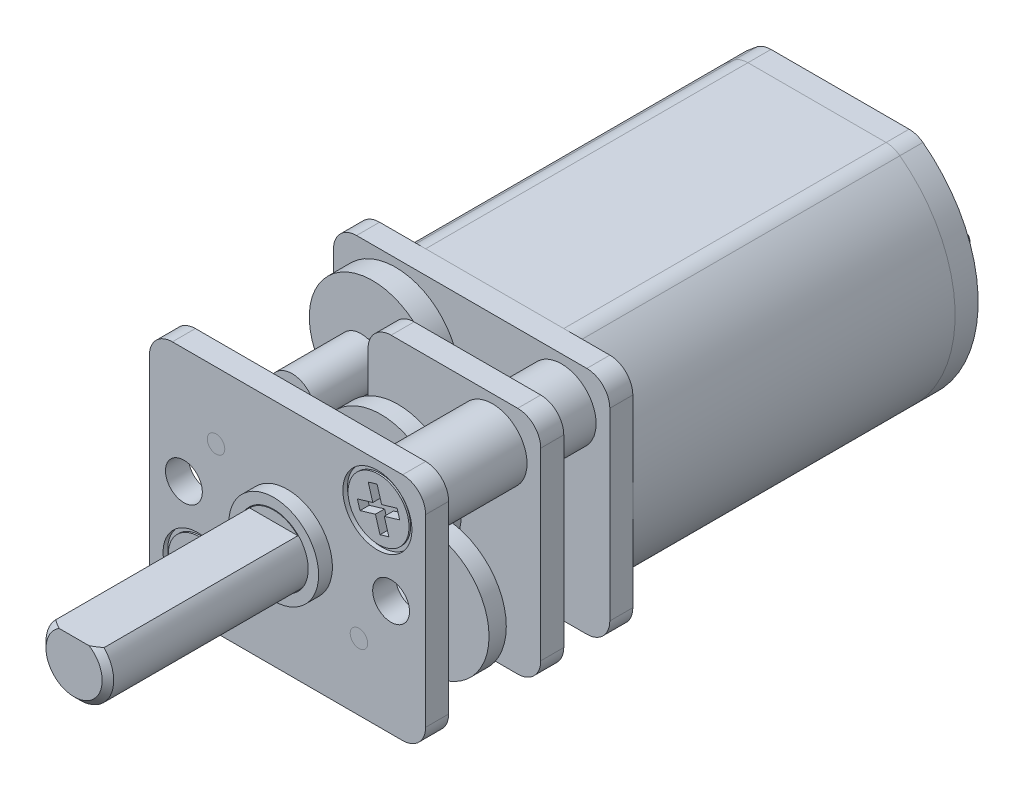
from build123d import *

# Parameters (mm, degrees)
BOSS_EXTRUDE1_DEPTH    = 7.5
FILLET3_R              = 1
BOSS_EXTRUDE2_DEPTH    = 1
BOSS_EXTRUDE3_START    = 9
BOSS_EXTRUDE3_DEPTH    = 1
SKETCH7_R              = 0.5
BOSS_EXTRUDE5_DEPTH    = 8
BOSS_EXTRUDE5_2_DEPTH  = 8
BOSS_EXTRUDE8_START    = 2
BOSS_EXTRUDE8_DEPTH    = 1
SKETCH5_R              = 0.75
SKETCH5_R_2            = 0.38
CUT_EXTRUDE1_DEPTH     = 9
SKETCH8_R              = 0.5
SKETCH8_R_2            = 0.38
CUT_EXTRUDE2_DEPTH     = 1
BOSS_EXTRUDE6_START    = 0.2
SKETCH9_R              = 2.75
SKETCH9_R_2            = 0.5
BOSS_EXTRUDE6_DEPTH    = 1
BOSS_EXTRUDE16_START   = 0.1
SKETCH9_3_R            = 1
SKETCH9_3_R_2          = 0.75
BOSS_EXTRUDE16_DEPTH   = 1.3
SKETCH6_R              = 1.95
SKETCH6_R_2            = 0.75
BOSS_EXTRUDE4_DEPTH    = 0.6
BOSS_EXTRUDE7_START    = 0.5
SKETCH10_R             = 1
SKETCH10_R_2           = 0.5
BOSS_EXTRUDE7_DEPTH    = 3
SKETCH12_R             = 1.5
SKETCH12_R_2           = 0.75
BOSS_EXTRUDE9_DEPTH    = 2
BOSS_EXTRUDE9_2_DEPTH  = 2
BOSS_EXTRUDE10_START   = 3
SKETCH12_2_R           = 1.5
SKETCH12_2_R_2         = 0.75
BOSS_EXTRUDE10_DEPTH   = 4
BOSS_EXTRUDE10_2_DEPTH = 4
SKETCH13_R             = 1.5
CUT_EXTRUDE3_DEPTH     = 7.2
SKETCH14_R             = 1.5
CUT_EXTRUDE4_DEPTH     = 0.2
CHAMFER1_SIZE          = 0.5
BOSS_EXTRUDE11_START   = 0.2
SKETCH15_R             = 2.75
BOSS_EXTRUDE11_DEPTH   = 0.75
BOSS_EXTRUDE12_START   = 0.2
SKETCH16_R             = 1
BOSS_EXTRUDE12_DEPTH   = 1.15
BOSS_EXTRUDE13_START   = 0.4
SKETCH17_R             = 2.75
BOSS_EXTRUDE13_DEPTH   = 0.75
BOSS_EXTRUDE14_START   = 0.2
SKETCH18_R             = 1
BOSS_EXTRUDE14_DEPTH   = 1.5
SKETCH19_R             = 0.5
CUT_EXTRUDE5_DEPTH     = 23.8
SKETCH20_R             = 2.75
BOSS_EXTRUDE15_DEPTH   = 1
SKETCH21_R             = 0.5
CUT_EXTRUDE6_DEPTH     = 7.8
CHAMFER2_SIZE          = 0.25
CUT_EXTRUDE7_DEPTH     = 8.67
SKETCH24_R             = 0.8
CUT_EXTRUDE8_DEPTH     = 1
CUT_EXTRUDE9_DEPTH     = 1
BOSS_EXTRUDE17_DEPTH   = 1
SKETCH27_R             = 2.5
BOSS_EXTRUDE18_DEPTH   = 1.5
SKETCH28_W             = 0.3
SKETCH28_H             = 1.5
BOSS_EXTRUDE19_DEPTH   = 2
BOSS_EXTRUDE19_2_DEPTH = 2
FILLET1_R              = 0.7
FILLET2_R              = 0.7
CUT_EXTRUDE10_DEPTH    = 0.4


with BuildPart() as part:
    # Sketch1 → Boss-Extrude1 (new body, symmetric)
    with BuildSketch(Plane.XY):
        with BuildLine():
            Line((3.31662479, 5), (-3.31662479, 5))
            ThreePointArc((-3.31662479, 5), (-6, 0), (-3.31662479, -5))
            Line((-3.31662479, -5), (3.31662479, -5))
            ThreePointArc((3.31662479, -5), (6, 0), (3.31662479, 5))
        make_face()
    extrude(amount=BOSS_EXTRUDE1_DEPTH, both=True)

    # Fillet3
    fillet3_edges = [part.edges().sort_by_distance(p)[0] for p in [
        (3.31662479, -5, 0),
        (-3.31662479, -5, 0),
        (-3.31662479, 5, 0),
        (3.31662479, 5, 0),
    ]]
    fillet(fillet3_edges, radius=FILLET3_R)

    # Sketch25 → Cut-Extrude9 (cut)
    with BuildSketch(Plane(origin=(0, 0, -7.5), x_dir=(-1, 0, 0), z_dir=(0, 0, -1))):
        with BuildLine():
            Line((-3, -5), (3, -5))
            ThreePointArc((3, -5), (3.316227766, -4.948683298), (3.6, -4.8))
            ThreePointArc((3.6, -4.8), (6, 0), (3.6, 4.8))
            ThreePointArc((3.6, 4.8), (3.316227766, 4.948683298), (3, 5))
            Line((3, 5), (-3, 5))
            ThreePointArc((-3, 5), (-3.316227766, 4.948683298), (-3.6, 4.8))
            ThreePointArc((-3.6, 4.8), (-6, 0), (-3.6, -4.8))
            ThreePointArc((-3.6, -4.8), (-3.316227766, -4.948683298), (-3, -5))
        make_face()
    extrude(amount=-CUT_EXTRUDE9_DEPTH, mode=Mode.SUBTRACT)


with BuildPart() as body_2:
    # Sketch2 → Boss-Extrude2 (new body)
    with BuildSketch(Plane.XY.offset(7.5)):
        with BuildLine():
            Line((-5, -5), (5, -5))
            ThreePointArc((5, -5), (5.707106781, -4.707106781), (6, -4))
            Line((6, -4), (6, 4))
            ThreePointArc((6, 4), (5.707106781, 4.707106781), (5, 5))
            Line((5, 5), (-5, 5))
            ThreePointArc((-5, 5), (-5.707106781, 4.707106781), (-6, 4))
            Line((-6, 4), (-6, -4))
            ThreePointArc((-6, -4), (-5.707106781, -4.707106781), (-5, -5))
        make_face()
    extrude(amount=BOSS_EXTRUDE2_DEPTH)


with BuildPart() as body_3:
    # Sketch2_2 → Boss-Extrude3 (new body)
    with BuildSketch(Plane.XY.offset(7.5).offset(BOSS_EXTRUDE3_START)):
        with BuildLine():
            Line((-5, -5), (5, -5))
            ThreePointArc((5, -5), (5.707106781, -4.707106781), (6, -4))
            Line((6, -4), (6, 4))
            ThreePointArc((6, 4), (5.707106781, 4.707106781), (5, 5))
            Line((5, 5), (-5, 5))
            ThreePointArc((-5, 5), (-5.707106781, 4.707106781), (-6, 4))
            Line((-6, 4), (-6, -4))
            ThreePointArc((-6, -4), (-5.707106781, -4.707106781), (-5, -5))
        make_face()
    extrude(amount=-BOSS_EXTRUDE3_DEPTH)


with BuildPart() as body_4:
    # Sketch7 → Boss-Extrude5 (new body)
    with BuildSketch(Plane.XY.offset(8.5)):
        with Locations((-3.104083332, 2.104083332)):
            Circle(SKETCH7_R)
    extrude(amount=BOSS_EXTRUDE5_DEPTH)


with BuildPart() as body_5:
    # Sketch7 → Boss-Extrude5 2 (new body)
    with BuildSketch(Plane.XY.offset(8.5)):
        with Locations((3.104083332, -2.104083332)):
            Circle(SKETCH7_R)
    extrude(amount=BOSS_EXTRUDE5_2_DEPTH)


with BuildPart() as body_6:
    # Sketch11 → Boss-Extrude8 (new body)
    with BuildSketch(Plane.XY.offset(8.5).offset(BOSS_EXTRUDE8_START)):
        with BuildLine():
            Line((-5, -1.25), (-2.5, -1.25))
            ThreePointArc((-2.5, -1.25), (-1.792893219, -0.957106781), (-1.5, -0.25))
            Line((-1.5, -0.25), (-1.5, 4))
            ThreePointArc((-1.5, 4), (-1.207106781, 4.707106781), (-0.5, 5))
            Line((-0.5, 5), (5, 5))
            ThreePointArc((5, 5), (5.707106781, 4.707106781), (6, 4))
            Line((6, 4), (6, -4))
            ThreePointArc((6, -4), (5.707106781, -4.707106781), (5, -5))
            Line((5, -5), (-5, -5))
            ThreePointArc((-5, -5), (-5.707106781, -4.707106781), (-6, -4))
            Line((-6, -4), (-6, -2.25))
            ThreePointArc((-6, -2.25), (-5.707106781, -1.542893219), (-5, -1.25))
        make_face()
    extrude(amount=BOSS_EXTRUDE8_DEPTH)


with BuildPart() as cut_extrude1_tool:
    # Sketch5 → Cut-Extrude1 (new body)
    with BuildSketch(Plane.XY.offset(16.5)):
        Circle(SKETCH5_R)
        with Locations((-3.104083332, 2.104083332)):
            Circle(SKETCH5_R_2)
        with Locations((3.104083332, -2.104083332)):
            Circle(SKETCH5_R_2)
        with Locations((3.904344047, 3.123475238)):
            Circle(SKETCH5_R)
        with Locations((-3.904344047, -3.123475238)):
            Circle(SKETCH5_R)
    extrude(amount=-CUT_EXTRUDE1_DEPTH)


with BuildPart() as body_2_1:
    add(body_2.part)

    # Cut-Extrude1: cut by cut_extrude1_tool
    add(cut_extrude1_tool.part, mode=Mode.SUBTRACT)


with BuildPart() as body_3_1:
    add(body_3.part)

    # Cut-Extrude1: cut by cut_extrude1_tool
    add(cut_extrude1_tool.part, mode=Mode.SUBTRACT)

    # Sketch6 → Boss-Extrude4 (add)
    with BuildSketch(Plane.XY.offset(16.5)):
        Circle(SKETCH6_R)
        Circle(SKETCH6_R_2, mode=Mode.SUBTRACT)
    extrude(amount=BOSS_EXTRUDE4_DEPTH)

    # Sketch13 → Cut-Extrude3 (cut)
    with BuildSketch(Plane.XY.offset(17.1)):
        Circle(SKETCH13_R)
    extrude(amount=-CUT_EXTRUDE3_DEPTH, mode=Mode.SUBTRACT)

    # Sketch14 → Cut-Extrude4 (cut)
    with BuildSketch(Plane.XY.offset(16.5)):
        with Locations((3.904344047, 3.123475238)):
            Circle(SKETCH14_R)
        with Locations((-3.904344047, -3.123475238)):
            Circle(SKETCH14_R)
    extrude(amount=-CUT_EXTRUDE4_DEPTH, mode=Mode.SUBTRACT)

    # Chamfer1
    chamfer1_edges = [body_3_1.edges().sort_by_distance(p)[0] for p in [
        (3.154344047, 3.123475238, 16.3),
        (-4.654344047, -3.123475238, 16.3),
    ]]
    chamfer(chamfer1_edges, length=CHAMFER1_SIZE)

    # Sketch24 → Cut-Extrude8 (cut)
    with BuildSketch(Plane.XY.offset(16.5)):
        with Locations((4.5, 0)):
            Circle(SKETCH24_R)
        with Locations((-4.5, 0)):
            Circle(SKETCH24_R)
    extrude(amount=-CUT_EXTRUDE8_DEPTH, mode=Mode.SUBTRACT)


with BuildPart() as body_6_1:
    add(body_6.part)

    # Cut-Extrude1: cut by cut_extrude1_tool
    add(cut_extrude1_tool.part, mode=Mode.SUBTRACT)


with BuildPart() as cut_extrude2_tool:
    # Sketch8 → Cut-Extrude2 (new body)
    with BuildSketch(Plane.XY.offset(16.5)):
        with Locations((-3.104083332, 2.104083332)):
            Circle(SKETCH8_R)
        with Locations((-3.104083332, 2.104083332)):
            Circle(SKETCH8_R_2, mode=Mode.SUBTRACT)
        with Locations((3.104083332, -2.104083332)):
            Circle(SKETCH8_R)
        with Locations((3.104083332, -2.104083332)):
            Circle(SKETCH8_R_2, mode=Mode.SUBTRACT)
    extrude(amount=-CUT_EXTRUDE2_DEPTH)


with BuildPart() as body_4_1:
    add(body_4.part)

    # Cut-Extrude2: cut by cut_extrude2_tool
    add(cut_extrude2_tool.part, mode=Mode.SUBTRACT)


with BuildPart() as body_5_1:
    add(body_5.part)

    # Cut-Extrude2: cut by cut_extrude2_tool
    add(cut_extrude2_tool.part, mode=Mode.SUBTRACT)


with BuildPart() as body_7:
    # Sketch9 → Boss-Extrude6 (new body)
    with BuildSketch(Plane.XY.offset(8.5).offset(BOSS_EXTRUDE6_START)):
        with Locations((-3.104083332, 2.104083332)):
            Circle(SKETCH9_R)
        with Locations((-3.104083332, 2.104083332)):
            Circle(SKETCH9_R_2, mode=Mode.SUBTRACT)
    extrude(amount=BOSS_EXTRUDE6_DEPTH)


with BuildPart() as body_8:
    # Sketch9_3 → Boss-Extrude16 (new body)
    with BuildSketch(Plane.XY.offset(8.5).offset(BOSS_EXTRUDE16_START)):
        Circle(SKETCH9_3_R)
        Circle(SKETCH9_3_R_2, mode=Mode.SUBTRACT)
        Circle(SKETCH9_3_R_2)
    extrude(amount=BOSS_EXTRUDE16_DEPTH)


with BuildPart() as body_9:
    # Sketch10 → Boss-Extrude7 (new body)
    with BuildSketch(Plane.XY.offset(9.7).offset(BOSS_EXTRUDE7_START)):
        with Locations((-3.104083332, 2.104083332)):
            Circle(SKETCH10_R)
        with Locations((-3.104083332, 2.104083332)):
            Circle(SKETCH10_R_2, mode=Mode.SUBTRACT)
    extrude(amount=BOSS_EXTRUDE7_DEPTH)


with BuildPart() as body_10:
    # Sketch12 → Boss-Extrude9 (new body)
    with BuildSketch(Plane.XY.offset(8.5)):
        with Locations((-3.904344047, -3.123475238)):
            Circle(SKETCH12_R)
        with Locations((-3.904344047, -3.123475238)):
            Circle(SKETCH12_R_2, mode=Mode.SUBTRACT)
    extrude(amount=BOSS_EXTRUDE9_DEPTH)


with BuildPart() as body_11:
    # Sketch12 → Boss-Extrude9 2 (new body)
    with BuildSketch(Plane.XY.offset(8.5)):
        with Locations((3.904344047, 3.123475238)):
            Circle(SKETCH12_R)
        with Locations((3.904344047, 3.123475238)):
            Circle(SKETCH12_R_2, mode=Mode.SUBTRACT)
    extrude(amount=BOSS_EXTRUDE9_2_DEPTH)


with BuildPart() as body_12:
    # Sketch12_2 → Boss-Extrude10 (new body)
    with BuildSketch(Plane.XY.offset(8.5).offset(BOSS_EXTRUDE10_START)):
        with Locations((-3.904344047, -3.123475238)):
            Circle(SKETCH12_2_R)
        with Locations((-3.904344047, -3.123475238)):
            Circle(SKETCH12_2_R_2, mode=Mode.SUBTRACT)
    extrude(amount=BOSS_EXTRUDE10_DEPTH)


with BuildPart() as body_13:
    # Sketch12_2 → Boss-Extrude10 2 (new body)
    with BuildSketch(Plane.XY.offset(8.5).offset(BOSS_EXTRUDE10_START)):
        with Locations((3.904344047, 3.123475238)):
            Circle(SKETCH12_2_R)
        with Locations((3.904344047, 3.123475238)):
            Circle(SKETCH12_2_R_2, mode=Mode.SUBTRACT)
    extrude(amount=BOSS_EXTRUDE10_2_DEPTH)


with BuildPart() as body_14:
    # Sketch15 → Boss-Extrude11 (new body)
    with BuildSketch(Plane.XY.offset(11.5).offset(BOSS_EXTRUDE11_START)):
        Circle(SKETCH15_R)
    extrude(amount=BOSS_EXTRUDE11_DEPTH)


with BuildPart() as body_15:
    # Sketch16 → Boss-Extrude12 (new body)
    with BuildSketch(Plane.XY.offset(12.45).offset(BOSS_EXTRUDE12_START)):
        Circle(SKETCH16_R)
    extrude(amount=BOSS_EXTRUDE12_DEPTH)


with BuildPart() as body_16:
    # Sketch17 → Boss-Extrude13 (new body)
    with BuildSketch(Plane.XY.offset(12.45).offset(BOSS_EXTRUDE13_START)):
        with Locations((3.104083332, -2.104083332)):
            Circle(SKETCH17_R)
    extrude(amount=BOSS_EXTRUDE13_DEPTH)


with BuildPart() as body_17:
    # Sketch18 → Boss-Extrude14 (new body)
    with BuildSketch(Plane.XY.offset(13.6).offset(BOSS_EXTRUDE14_START)):
        with Locations((3.104083332, -2.104083332)):
            Circle(SKETCH18_R)
    extrude(amount=BOSS_EXTRUDE14_DEPTH)


with BuildPart() as cut_extrude5_tool:
    # Sketch19 → Cut-Extrude5 (new body, through all)
    with BuildSketch(Plane.XY.offset(15.3)):
        with Locations((3.104083332, -2.104083332)):
            Circle(SKETCH19_R)
    extrude(amount=-CUT_EXTRUDE5_DEPTH)


with BuildPart() as body_17_1:
    add(body_17.part)

    # Cut-Extrude5: cut by cut_extrude5_tool
    add(cut_extrude5_tool.part, mode=Mode.SUBTRACT)


with BuildPart() as body_16_1:
    add(body_16.part)

    # Cut-Extrude5: cut by cut_extrude5_tool
    add(cut_extrude5_tool.part, mode=Mode.SUBTRACT)


with BuildPart() as body_6_2:
    add(body_6_1.part)

    # Cut-Extrude5: cut by cut_extrude5_tool
    add(cut_extrude5_tool.part, mode=Mode.SUBTRACT)


with BuildPart() as body_18:
    # Sketch20 → Boss-Extrude15 (new body)
    with BuildSketch(Plane.XY.offset(15.3)):
        Circle(SKETCH20_R)
    extrude(amount=-BOSS_EXTRUDE15_DEPTH)


with BuildPart() as cut_extrude6_tool:
    # Sketch21 → Cut-Extrude6 (new body)
    with BuildSketch(Plane.XY.offset(15.3)):
        Circle(SKETCH21_R)
    extrude(amount=-CUT_EXTRUDE6_DEPTH)


with BuildPart() as body_8_1:
    add(body_8.part)

    # Cut-Extrude6: cut by cut_extrude6_tool
    add(cut_extrude6_tool.part, mode=Mode.SUBTRACT)


with BuildPart() as body_14_1:
    add(body_14.part)

    # Cut-Extrude6: cut by cut_extrude6_tool
    add(cut_extrude6_tool.part, mode=Mode.SUBTRACT)


with BuildPart() as body_15_1:
    add(body_15.part)

    # Cut-Extrude6: cut by cut_extrude6_tool
    add(cut_extrude6_tool.part, mode=Mode.SUBTRACT)


with BuildPart() as body_18_1:
    add(body_18.part)

    # Cut-Extrude6: cut by cut_extrude6_tool
    add(cut_extrude6_tool.part, mode=Mode.SUBTRACT)


with BuildPart() as body_19:
    # Sketch22 → Revolve1 (revolve)
    with BuildSketch(Plane(origin=(0, 0, 0), x_dir=(1, 0, 0), z_dir=(0, 1, 0))):
        Polygon((-0.5, -7.5), (-0.5, -15.3), (-1.47, -15.3), (-1.47, -25.77), (0, -25.77), (0, -7.5), align=None)
    revolve(axis=Axis((0, 0, 0), (0, 0, 1)))

    # Chamfer2
    chamfer2_edges = [body_19.edges().sort_by_distance(p)[0] for p in [
        (1.47, 0, 25.77),
    ]]
    chamfer(chamfer2_edges, length=CHAMFER2_SIZE)

    # Sketch23 → Cut-Extrude7 (cut)
    with BuildSketch(Plane.XY.offset(25.77)):
        with BuildLine():
            Line((1.048808848, 1.03), (-1.048808848, 1.03))
            ThreePointArc((-1.048808848, 1.03), (0, 1.47), (1.048808848, 1.03))
        make_face()
    extrude(amount=-CUT_EXTRUDE7_DEPTH, mode=Mode.SUBTRACT)


with BuildPart() as body_20:
    # Sketch26 → Boss-Extrude17 (new body)
    with BuildSketch(Plane(origin=(0, 0, -6.5), x_dir=(-1, 0, 0), z_dir=(0, 0, -1))):
        with BuildLine():
            Line((-3, -5), (3, -5))
            ThreePointArc((3, -5), (3.316227766, -4.948683298), (3.6, -4.8))
            ThreePointArc((3.6, -4.8), (6, 0), (3.6, 4.8))
            ThreePointArc((3.6, 4.8), (3.316227766, 4.948683298), (3, 5))
            Line((3, 5), (-3, 5))
            ThreePointArc((-3, 5), (-3.316227766, 4.948683298), (-3.6, 4.8))
            ThreePointArc((-3.6, 4.8), (-6, 0), (-3.6, -4.8))
            ThreePointArc((-3.6, -4.8), (-3.316227766, -4.948683298), (-3, -5))
        make_face()
    extrude(amount=BOSS_EXTRUDE17_DEPTH)

    # Sketch27 → Boss-Extrude18 (add)
    with BuildSketch(Plane(origin=(0, 0, -7.5), x_dir=(-1, 0, 0), z_dir=(0, 0, -1))):
        Circle(SKETCH27_R)
    extrude(amount=BOSS_EXTRUDE18_DEPTH)


with BuildPart() as body_21:
    # Sketch28 → Boss-Extrude19 (new body)
    with BuildSketch(Plane(origin=(0, 0, -7.5), x_dir=(-1, 0, 0), z_dir=(0, 0, -1))):
        with Locations((3.5, 0)):
            Rectangle(SKETCH28_W, SKETCH28_H)
    extrude(amount=BOSS_EXTRUDE19_DEPTH)

    # Fillet1
    fillet1_edges = [body_21.edges().sort_by_distance(p)[0] for p in [
        (-3.5, -0.75, -9.5),
        (-3.5, 0.75, -9.5),
    ]]
    fillet(fillet1_edges, radius=FILLET1_R)


with BuildPart() as body_22:
    # Sketch28 → Boss-Extrude19 2 (new body)
    with BuildSketch(Plane(origin=(0, 0, -7.5), x_dir=(-1, 0, 0), z_dir=(0, 0, -1))):
        with Locations((-3.5, 0)):
            Rectangle(SKETCH28_W, SKETCH28_H)
    extrude(amount=BOSS_EXTRUDE19_2_DEPTH)

    # Fillet2
    fillet2_edges = [body_22.edges().sort_by_distance(p)[0] for p in [
        (3.5, -0.75, -9.5),
        (3.5, 0.75, -9.5),
    ]]
    fillet(fillet2_edges, radius=FILLET2_R)


with BuildPart() as body_23:
    # Sketch29 → Revolve2 (revolve)
    with BuildSketch(Plane(origin=(0, 0, 0), x_dir=(0.780868809, 0.624695048, 0), z_dir=(0.624695048, -0.780868809, 0))):
        Polygon((5.7, 7.5), (5.7, 15.755), (6.325, 16.38), (6.325, 16.45), (5, 16.45), (5, 7.5), align=None)
    revolve(axis=Axis((3.904344047, 3.123475238, 16.5), (0, 0, 1)))


with BuildPart() as body_24:
    # Sketch29_3 → Revolve3 (revolve)
    with BuildSketch(Plane(origin=(0, 0, 0), x_dir=(0.780868809, 0.624695048, 0), z_dir=(0.624695048, -0.780868809, 0))):
        Polygon((-5.7, 7.5), (-5.7, 15.755), (-6.325, 16.38), (-6.325, 16.45), (-5, 16.45), (-5, 7.5), align=None)
    revolve(axis=Axis((-3.904344047, -3.123475238, 16.5), (0, 0, 1)))


with BuildPart() as cut_extrude10_tool:
    # Sketch30 → Cut-Extrude10 (new body)
    with BuildSketch(Plane.XY.offset(16.45)):
        Polygon((-3.774222132, -2.210749492), (-4.020996733, -2.865808494), (-4.676055735, -2.619033892), (-4.817069793, -2.993353322), (-4.162010791, -3.240127924), (-4.408785393, -3.895186926), (-4.034465963, -4.036200984), (-3.787691361, -3.381141982), (-3.132632359, -3.627916583), (-2.991618301, -3.253597153), (-3.646677303, -3.006822552), (-3.399902702, -2.35176355), align=None)
        Polygon((3.456494168, 3.929347737), (3.65569802, 3.258290493), (2.984640775, 3.059086641), (3.098471548, 2.675625358), (3.769528792, 2.87482921), (3.968732644, 2.203771966), (4.352193927, 2.317602738), (4.152990075, 2.988659983), (4.824047319, 3.187863835), (4.710216547, 3.571325117), (4.039159302, 3.372121265), (3.83995545, 4.04317851), align=None)
    extrude(amount=-CUT_EXTRUDE10_DEPTH)


with BuildPart() as body_23_1:
    add(body_23.part)

    # Cut-Extrude10: cut by cut_extrude10_tool
    add(cut_extrude10_tool.part, mode=Mode.SUBTRACT)


with BuildPart() as body_24_1:
    add(body_24.part)

    # Cut-Extrude10: cut by cut_extrude10_tool
    add(cut_extrude10_tool.part, mode=Mode.SUBTRACT)


solid = Compound([part.part, body_2_1.part, body_3_1.part, body_4_1.part, body_5_1.part, body_7.part, body_9.part, body_10.part, body_11.part, body_12.part, body_13.part, body_17_1.part, body_16_1.part, body_6_2.part, body_8_1.part, body_14_1.part, body_15_1.part, body_18_1.part, body_19.part, body_20.part, body_21.part, body_22.part, body_23_1.part, body_24_1.part])
